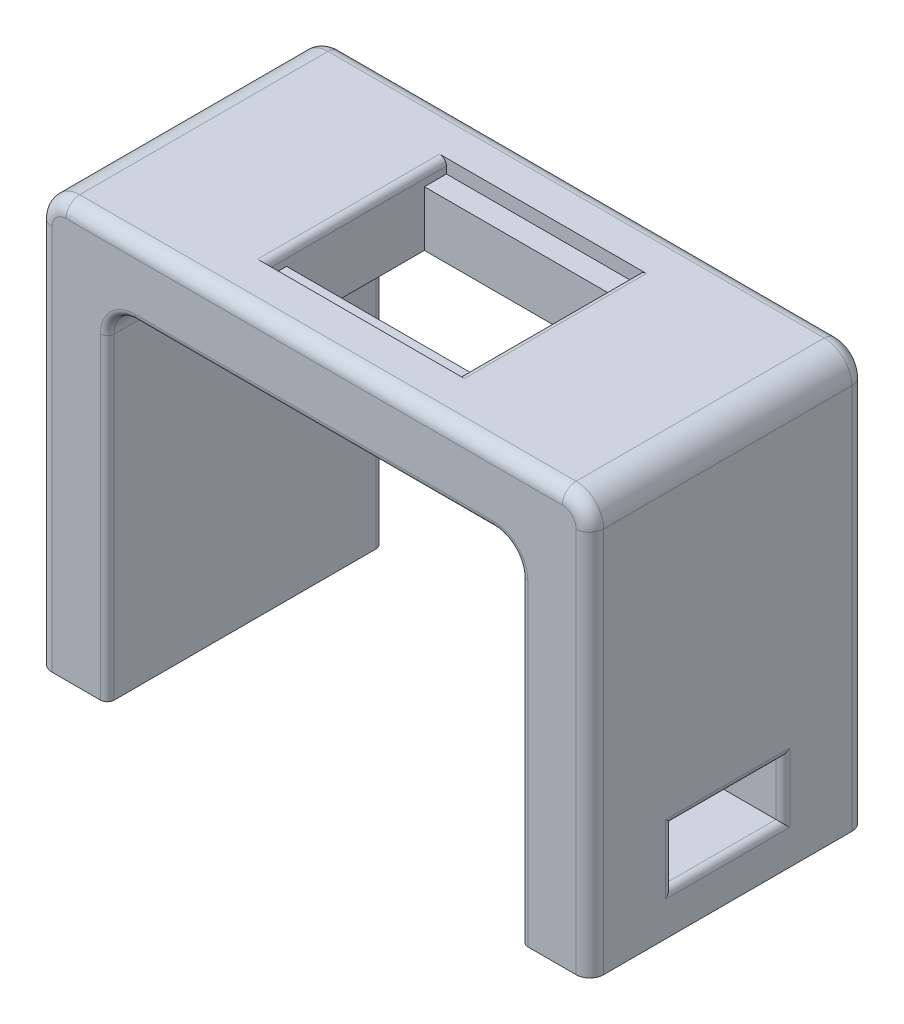
from build123d import *

# Parameters (mm, degrees)
BOSS_EXTRUDE1_DEPTH = 50.8
FILLET1_R           = 5.08
SKETCH2_W           = 35.56
SKETCH2_H           = 33.528
CUT_EXTRUDE1_DEPTH  = 2.54
SKETCH4_W           = 35.56
SKETCH4_H           = 25.4
CUT_EXTRUDE2_DEPTH  = 74.66
FILLET2_R           = 1.27
CUT_EXTRUDE3_REACH  = 103.6
SKETCH6_W           = 20.32
SKETCH6_H           = 10.16
FILLET3_R           = 2.54
FILLET4_R           = 1.27
FILLET5_R           = 1.27


with BuildPart() as part:
    # Sketch1 → Boss-Extrude1 (new body)
    with BuildSketch(Plane.XY):
        Polygon((0, 0), (0, 76.2), (101.6, 76.2), (101.6, 0), (88.9, 0), (88.9, 63.5), (12.7, 63.5), (12.7, 0), align=None)
    extrude(amount=BOSS_EXTRUDE1_DEPTH)

    # Fillet1
    fillet1_edges = [part.edges().sort_by_distance(p)[0] for p in [
        (0, 76.2, 25.4),
        (101.6, 76.2, 25.4),
        (88.9, 63.5, 25.4),
        (12.7, 63.5, 25.4),
    ]]
    fillet(fillet1_edges, radius=FILLET1_R)

    # Sketch2 → Cut-Extrude1 (cut)
    with BuildSketch(Plane(origin=(0, 76.2, 0), x_dir=(1, 0, 0), z_dir=(0, 1, 0))):
        with Locations((50.8, -25.4)):
            Rectangle(SKETCH2_W, SKETCH2_H)
    extrude(amount=-CUT_EXTRUDE1_DEPTH, mode=Mode.SUBTRACT)

    # Sketch4 → Cut-Extrude2 (cut, through all)
    with BuildSketch(Plane(origin=(0, 73.66, 0), x_dir=(1, 0, 0), z_dir=(0, 1, 0))):
        with Locations((50.8, -25.4)):
            Rectangle(SKETCH4_W, SKETCH4_H)
    extrude(amount=-CUT_EXTRUDE2_DEPTH, mode=Mode.SUBTRACT)

    # Fillet2
    fillet2_edges = [part.edges().sort_by_distance(p)[0] for p in [
        (68.58, 76.2, 25.4),
        (33.02, 76.2, 25.4),
    ]]
    fillet(fillet2_edges, radius=FILLET2_R)

    # Sketch6 → Cut-Extrude3 (cut, up to next)
    with BuildSketch(Plane(origin=(101.6, 0, 0), x_dir=(0, 0, -1), z_dir=(1, 0, 0)), mode=Mode.PRIVATE) as cut_extrude3_sk1:
        with Locations((-25.4, 12.7)):
            Rectangle(SKETCH6_W, SKETCH6_H)
    cut_extrude3_tool1 = extrude(cut_extrude3_sk1.sketch, amount=-CUT_EXTRUDE3_REACH, mode=Mode.PRIVATE) & part.part
    add(cut_extrude3_tool1.solids().sort_by_distance((101.6, 12.7, 25.4))[0], mode=Mode.SUBTRACT)

    # Fillet3
    fillet3_edges = [part.edges().sort_by_distance(p)[0] for p in [
        (101.6, 35.56, 50.8),
        (50.8, 76.2, 0),
        (50.8, 76.2, 50.8),
        (0, 35.56, 0),
        (1.487897552, 74.712102448, 0),
        (100.112102448, 74.712102448, 0),
        (0, 35.56, 50.8),
        (1.487897552, 74.712102448, 50.8),
        (100.112102448, 74.712102448, 50.8),
        (101.6, 35.56, 0),
    ]]
    fillet(fillet3_edges, radius=FILLET3_R)

    # Fillet4
    fillet4_edges = [part.edges().sort_by_distance(p)[0] for p in [
        (101.6, 12.7, 35.56),
        (101.6, 17.78, 25.4),
        (101.6, 7.62, 25.4),
        (101.6, 12.7, 15.24),
    ]]
    fillet(fillet4_edges, radius=FILLET4_R)

    # Fillet5
    fillet5_edges = [part.edges().sort_by_distance(p)[0] for p in [
        (12.7, 29.21, 0),
        (88.9, 29.21, 0),
        (88.9, 29.21, 50.8),
        (50.8, 63.5, 0),
        (50.8, 63.5, 50.8),
        (87.412102448, 62.012102448, 0),
        (87.412102448, 62.012102448, 50.8),
        (14.187897552, 62.012102448, 0),
        (14.187897552, 62.012102448, 50.8),
        (12.7, 29.21, 50.8),
    ]]
    fillet(fillet5_edges, radius=FILLET5_R)


solid = part.part
